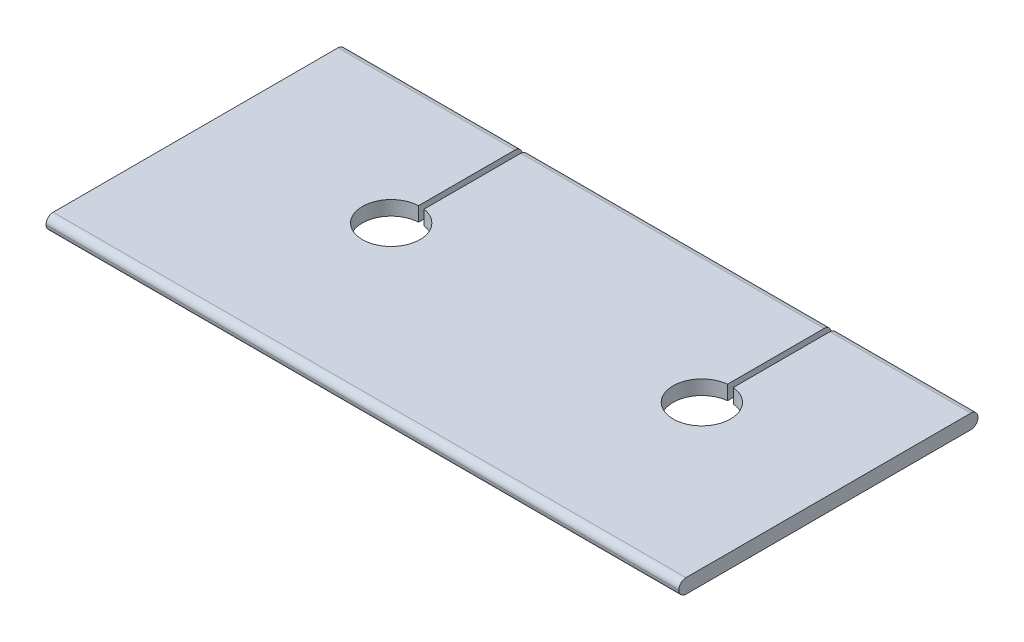
from build123d import *

# Parameters (mm, degrees)
BOSS_EXTRUDE1_DEPTH = 55
SKETCH2_W           = 0.5
SKETCH2_H           = 4.754059282
SKETCH2_H_2         = 4.044844813
CUT_EXTRUDE1_DEPTH  = 2.25


with BuildPart() as part:
    # Sketch1 → Boss-Extrude1 (new body)
    with BuildSketch(Plane(origin=(0, 0, 0), x_dir=(0, 0, -1), z_dir=(1, 0, 0))):
        with BuildLine():
            Line((12.38, 0.625), (-12.38, 0.625))
            ThreePointArc((-12.38, 0.625), (-12.818406204, 0.443406204), (-13, 0.005))
            Line((-13, 0.005), (-13, -0.005))
            ThreePointArc((-13, -0.005), (-12.818406204, -0.443406204), (-12.38, -0.625))
            Line((-12.38, -0.625), (12.38, -0.625))
            ThreePointArc((12.38, -0.625), (12.818406204, -0.443406204), (13, -0.005))
            Line((13, -0.005), (13, 0.005))
            ThreePointArc((13, 0.005), (12.818406204, 0.443406204), (12.38, 0.625))
        make_face()
    extrude(amount=BOSS_EXTRUDE1_DEPTH)

    # Sketch2 → Cut-Extrude1 (cut, through all)
    with BuildSketch(Plane(origin=(0, 0.625, 0), x_dir=(1, 0, 0), z_dir=(0, 1, 0))):
        with BuildLine():
            ThreePointArc((15.382256297, 3.997225745), (15.367075517, -0.996463715), (15.882256297, 3.97060319))
            Line((15.882256297, 3.97060319), (15.882256297, 12.38))
            Line((15.882256297, 12.38), (15.382256297, 12.38))
            Line((15.382256297, 12.38), (15.382256297, 3.997225745))
        make_face()
        with BuildLine():
            Line((42.746308765, 12.38), (42.246308765, 12.38))
            Line((42.246308765, 12.38), (42.246308765, 3.987094843))
            ThreePointArc((42.246308765, 3.987094843), (42.50370983, -0.999997247), (42.746308765, 3.98783681))
            Line((42.746308765, 3.98783681), (42.746308765, 12.38))
        make_face()
        with Locations((15.632256297, 14.757029641)):
            Rectangle(SKETCH2_W, SKETCH2_H)
        with Locations((42.496308765, 14.402422407)):
            Rectangle(SKETCH2_W, SKETCH2_H_2)
    extrude(amount=-CUT_EXTRUDE1_DEPTH, mode=Mode.SUBTRACT)


solid = part.part
